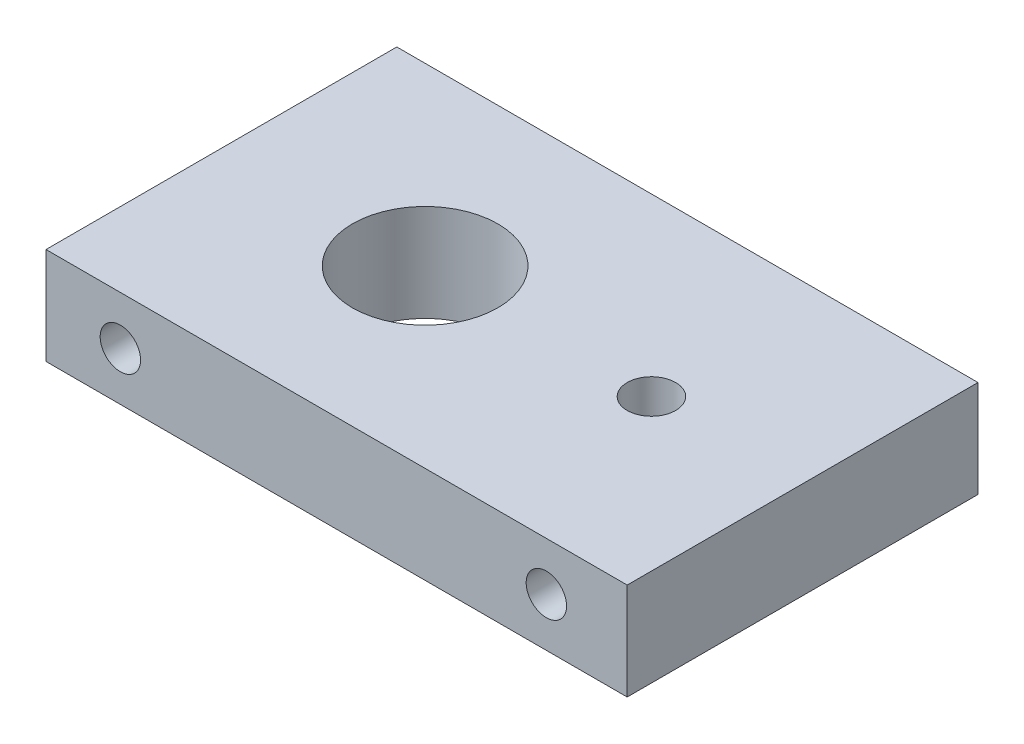
from build123d import *

# Parameters (mm, degrees)
SKIZZE3_W                            = 46.7
SKIZZE3_H                            = 6
AUFSATZ_LINEAR_AUSTRAGEN1_DEPTH      = 12.65
AUFSATZ_LINEAR_AUSTRAGEN1_DEPTH_BACK = 12.65
SKIZZE4_OUTSIDE_W                    = 59.39
SKIZZE4_OUTSIDE_H                    = 37.99
SKIZZE4_OUTSIDE_W_2                  = 35.95
SKIZZE4_OUTSIDE_H_2                  = 21.7
SCHNITT_LINEAR_AUSTRAGEN1_DEPTH      = 237
SKIZZE7_R                            = 4.5
SKIZZE7_R_2                          = 1.5
SCHNITT_LINEAR_AUSTRAGEN2_DEPTH      = 237
SCHNITT_LINEAR_START                 = -10.85
THREADHOLESSIDE_R                    = 1.25
SCHNITT_LINEAR_AUSTRAGEN3_DEPTH      = 6
SCHNITT_LINEAR_START_2               = 10.85
THREADHOLESSIDE_2_R                  = 1.25
SCHNITT_LINEAR_AUSTRAGEN4_DEPTH      = 6


with BuildPart() as part:
    # Skizze3 → Aufsatz-Linear austragen1 (new body, two sides)
    with BuildSketch(Plane.XY) as aufsatz_linear_austragen1_sk:
        with Locations((0, 234)):
            Rectangle(SKIZZE3_W, SKIZZE3_H)
    extrude(amount=AUFSATZ_LINEAR_AUSTRAGEN1_DEPTH)
    extrude(aufsatz_linear_austragen1_sk.sketch, amount=-AUFSATZ_LINEAR_AUSTRAGEN1_DEPTH_BACK)

    # Skizze4 outside → Schnitt-Linear austragen1 (cut)
    with BuildSketch(Plane(origin=(0, 0, 0), x_dir=(1, 0, 0), z_dir=(0, 1, 0))):
        Rectangle(SKIZZE4_OUTSIDE_W, SKIZZE4_OUTSIDE_H)
        with Locations((5.375, 0)):
            Rectangle(SKIZZE4_OUTSIDE_W_2, SKIZZE4_OUTSIDE_H_2, mode=Mode.SUBTRACT)
    extrude(amount=SCHNITT_LINEAR_AUSTRAGEN1_DEPTH, mode=Mode.SUBTRACT)

    # Skizze7 → Schnitt-Linear austragen2 (cut)
    with BuildSketch(Plane(origin=(0, 0, 0), x_dir=(1, 0, 0), z_dir=(0, 1, 0))):
        Circle(SKIZZE7_R)
        with Locations((14, 0)):
            Circle(SKIZZE7_R_2)
    extrude(amount=SCHNITT_LINEAR_AUSTRAGEN2_DEPTH, mode=Mode.SUBTRACT)

    # ThreadHolesSide → Schnitt-Linear austragen3 (cut)
    with BuildSketch(Plane.XY.offset(SCHNITT_LINEAR_START)):
        with Locations((18.35, 234)):
            Circle(THREADHOLESSIDE_R)
        with Locations((-8, 234)):
            Circle(THREADHOLESSIDE_R)
    extrude(amount=SCHNITT_LINEAR_AUSTRAGEN3_DEPTH, mode=Mode.SUBTRACT)

    # ThreadHolesSide_2 → Schnitt-Linear austragen4 (cut)
    with BuildSketch(Plane.XY.offset(SCHNITT_LINEAR_START_2)):
        with Locations((18.35, 234)):
            Circle(THREADHOLESSIDE_2_R)
        with Locations((-8, 234)):
            Circle(THREADHOLESSIDE_2_R)
        with Locations((18.35, 615)):
            Circle(THREADHOLESSIDE_2_R)
        with Locations((-8, 615)):
            Circle(THREADHOLESSIDE_2_R)
    extrude(amount=-SCHNITT_LINEAR_AUSTRAGEN4_DEPTH, mode=Mode.SUBTRACT)


solid = part.part
